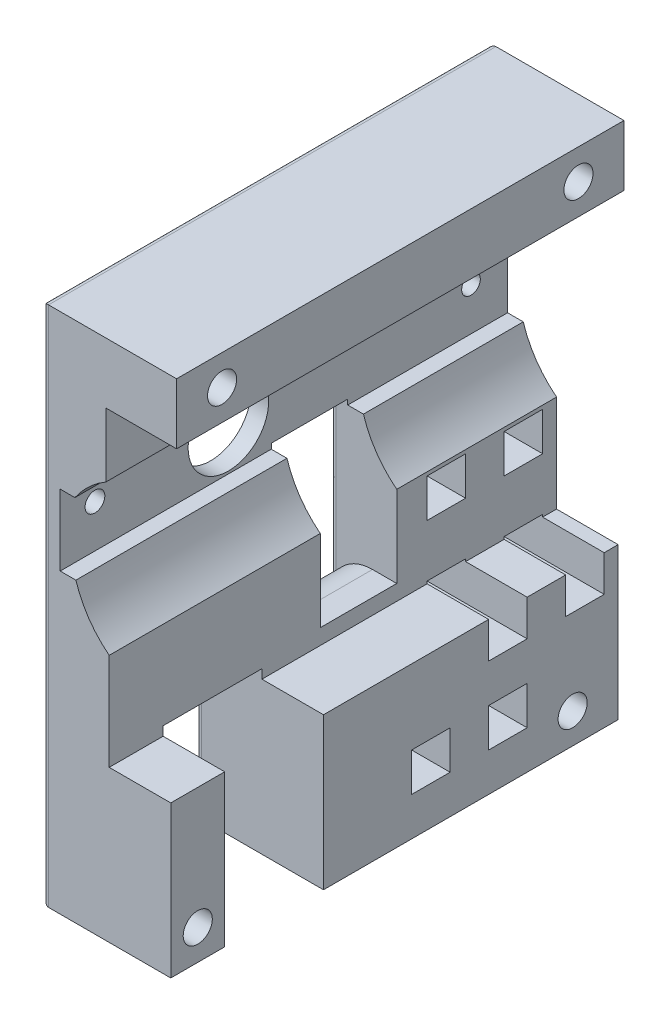
from build123d import *

# Parameters (mm, degrees)
PROFILEEXTRUDE_DEPTH    = 73.76
HOSEWINDOW_W            = 16.29
HOSEWINDOW_H            = 26.5
HOSEWINDOWCUT_DEPTH     = 23.11
CAGESCREWS_R            = 2.4
CAGESCREWSCUT_DEPTH     = 23.11
AXLEHOLECUT_DEPTH       = 23.11
SETSCREWHOLES_R         = 1.539432213
SETSCREWHOLES_R_2       = 1.628953018
SETSCREWHOLESCUT_DEPTH  = 23.11
VELOCITYWINDOW_W        = 12.61
VELOCITYWINDOW_H        = 22.29
VELOCITYWINDOWCUT_DEPTH = 23.11
FILLET3_R               = 7
TRIGGERRACKSLOTCUT_W    = 6.35
TRIGGERRACKSLOTCUT_H    = 6.35
RACKSLOTCUT_DEPTH       = 23.11
FILLET4_R               = 1


with BuildPart() as part:
    # Profile → ProfileExtrude (new body)
    with BuildSketch(Plane.XY):
        with BuildLine():
            Line((9.301269376, -54.194713793), (9.301269376, -29.194713793))
            Line((9.301269376, -29.194713793), (-0.848730624, -29.194713793))
            Line((-0.848730624, -29.194713793), (-0.848730624, -13.196583793))
            ThreePointArc((-0.848730624, -13.196583793), (-4.204324299, -9.619560571), (-6.340730624, -5.204713793))
            Line((-6.340730624, -5.204713793), (-8.928730624, -5.204713793))
            Line((-8.928730624, -5.204713793), (-8.928730624, 6.495286207))
            Line((-8.928730624, 6.495286207), (-6.509650624, 6.495286207))
            ThreePointArc((-6.509650624, 6.495286207), (-4.210311879, 9.168674207), (-1.388730624, 11.283536207))
            Line((-1.388730624, 11.283536207), (-1.388730624, 21.845286207))
            Line((-1.388730624, 21.845286207), (10.261269376, 21.845286207))
            Line((10.261269376, 21.845286207), (10.261269376, 31.845286207))
            Line((10.261269376, 31.845286207), (-11.848730624, 31.845286207))
            Line((-11.848730624, 31.845286207), (-11.848730624, -54.194713793))
            Line((-11.848730624, -54.194713793), (9.301269376, -54.194713793))
        make_face()
    extrude(amount=PROFILEEXTRUDE_DEPTH)

    # HoseWindow → HoseWindowCut (cut, through all)
    with BuildSketch(Plane.ZY.offset(11.848730624)):
        with Locations((56.725, -40.944713793)):
            Rectangle(HOSEWINDOW_W, HOSEWINDOW_H)
    extrude(amount=-HOSEWINDOWCUT_DEPTH, mode=Mode.SUBTRACT)

    # CageScrews → CageScrewsCut (cut, through all)
    with BuildSketch(Plane.ZY.offset(11.848730624)):
        with Locations((7.5, 26.845286207)):
            Circle(CAGESCREWS_R)
        with Locations((66.26, 26.845286207)):
            Circle(CAGESCREWS_R)
        with Locations((7.5, -49.194713793)):
            Circle(CAGESCREWS_R)
        with Locations((69.31, -49.194713793)):
            Circle(CAGESCREWS_R)
    extrude(amount=-CAGESCREWSCUT_DEPTH, mode=Mode.SUBTRACT)

    # AxleHole → AxleHoleCut (cut, through all)
    with BuildSketch(Plane.ZY.offset(11.848730624)):
        with BuildLine():
            Line((47.361, 8.359497151), (47.361, 6.740497151))
            Line((47.361, 6.740497151), (44.699, 6.740497151))
            Line((44.699, 6.740497151), (44.699, 8.359497151))
            ThreePointArc((44.699, 8.359497151), (46.03, -4.783713793), (47.361, 8.359497151))
        make_face()
    extrude(amount=-AXLEHOLECUT_DEPTH, mode=Mode.SUBTRACT)

    # SetScrewHoles → SetScrewHolesCut (cut, through all)
    with BuildSketch(Plane.ZY.offset(11.848730624)):
        with Locations((6.03, 1.855286207)):
            Circle(SETSCREWHOLES_R)
        with Locations((68.03, 1.855286207)):
            Circle(SETSCREWHOLES_R_2)
    extrude(amount=-SETSCREWHOLESCUT_DEPTH, mode=Mode.SUBTRACT)

    # VelocityWindow → VelocityWindowCut (cut, through all)
    with BuildSketch(Plane.ZY.offset(11.848730624)):
        with Locations((32.655, -15.499713793)):
            Rectangle(VELOCITYWINDOW_W, VELOCITYWINDOW_H)
    extrude(amount=-VELOCITYWINDOWCUT_DEPTH, mode=Mode.SUBTRACT)

    # Fillet3
    fillet3_edges = [part.edges().sort_by_distance(p)[0] for p in [
        (-11.848730624, -26.644713793, 32.655),
    ]]
    fillet(fillet3_edges, radius=FILLET3_R)

    # TriggerRackSlotCut → RackSlotCut (cut, through all)
    with BuildSketch(Plane.ZY.offset(11.848730624)):
        with Locations((18.175, -44.669713793)):
            Rectangle(TRIGGERRACKSLOTCUT_W, TRIGGERRACKSLOTCUT_H)
        with Locations((30.875, -44.669713793)):
            Rectangle(TRIGGERRACKSLOTCUT_W, TRIGGERRACKSLOTCUT_H)
        with Locations((5.475, -31.969713793)):
            Rectangle(TRIGGERRACKSLOTCUT_W, TRIGGERRACKSLOTCUT_H)
        with Locations((18.175, -31.969713793)):
            Rectangle(TRIGGERRACKSLOTCUT_W, TRIGGERRACKSLOTCUT_H)
        with Locations((5.475, -16.969713793)):
            Rectangle(TRIGGERRACKSLOTCUT_W, TRIGGERRACKSLOTCUT_H)
        with Locations((18.175, -16.969713793)):
            Rectangle(TRIGGERRACKSLOTCUT_W, TRIGGERRACKSLOTCUT_H)
    extrude(amount=-RACKSLOTCUT_DEPTH, mode=Mode.SUBTRACT)

    # Fillet4
    fillet4_edges = [part.edges().sort_by_distance(p)[0] for p in [
        (-11.848730624, -11.174713793, 73.76),
        (-11.848730624, -18.999713793, 26.35),
        (-11.848730624, -18.999713793, 38.96),
        (-11.848730624, -4.354713793, 32.655),
        (-11.848730624, -44.669713793, 15),
        (-11.848730624, -47.844713793, 18.175),
        (-11.848730624, -44.669713793, 21.35),
        (-11.848730624, -41.494713793, 18.175),
        (-11.848730624, -11.174713793, 0),
        (-11.848730624, -31.969713793, 2.3),
        (-11.848730624, -35.144713793, 5.475),
        (-11.848730624, -31.969713793, 8.65),
        (-11.848730624, -28.794713793, 5.475),
        (-11.848730624, -44.669713793, 27.7),
        (-11.848730624, -47.844713793, 30.875),
        (-11.848730624, -44.669713793, 34.05),
        (-11.848730624, -41.494713793, 30.875),
        (-11.848730624, -31.969713793, 15),
        (-11.848730624, -35.144713793, 18.175),
        (-11.848730624, -31.969713793, 21.35),
        (-11.848730624, -28.794713793, 18.175),
        (-11.848730624, -54.194713793, 69.315),
        (-11.848730624, 31.845286207, 36.88),
        (-11.848730624, -16.969713793, 2.3),
        (-11.848730624, -20.144713793, 5.475),
        (-11.848730624, -16.969713793, 8.65),
        (-11.848730624, -13.794713793, 5.475),
        (-11.848730624, -16.969713793, 15),
        (-11.848730624, -20.144713793, 18.175),
        (-11.848730624, -16.969713793, 21.35),
        (-11.848730624, -13.794713793, 18.175),
        (-11.848730624, -54.194713793, 24.29),
        (-11.848730624, -40.944713793, 64.87),
        (-11.848730624, -27.694713793, 56.725),
        (-11.848730624, -40.944713793, 48.58),
    ]]
    fillet(fillet4_edges, radius=FILLET4_R)


solid = part.part
